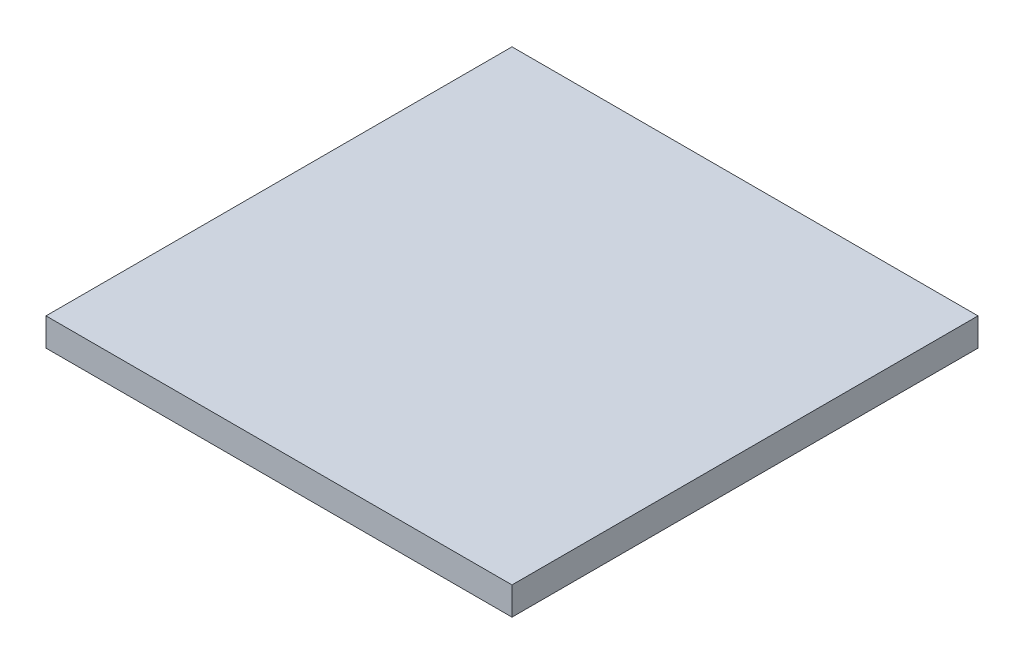
from build123d import *

# Parameters (mm, degrees)
SKETCH1_W           = 1270
SKETCH1_H           = 1270
BOSS_EXTRUDE1_DEPTH = 76.2


with BuildPart() as part:
    # Sketch1 → Boss-Extrude1 (new body)
    with BuildSketch(Plane(origin=(0, 0, 0), x_dir=(1, 0, 0), z_dir=(0, 1, 0))):
        Rectangle(SKETCH1_W, SKETCH1_H)
    extrude(amount=BOSS_EXTRUDE1_DEPTH)


solid = part.part
